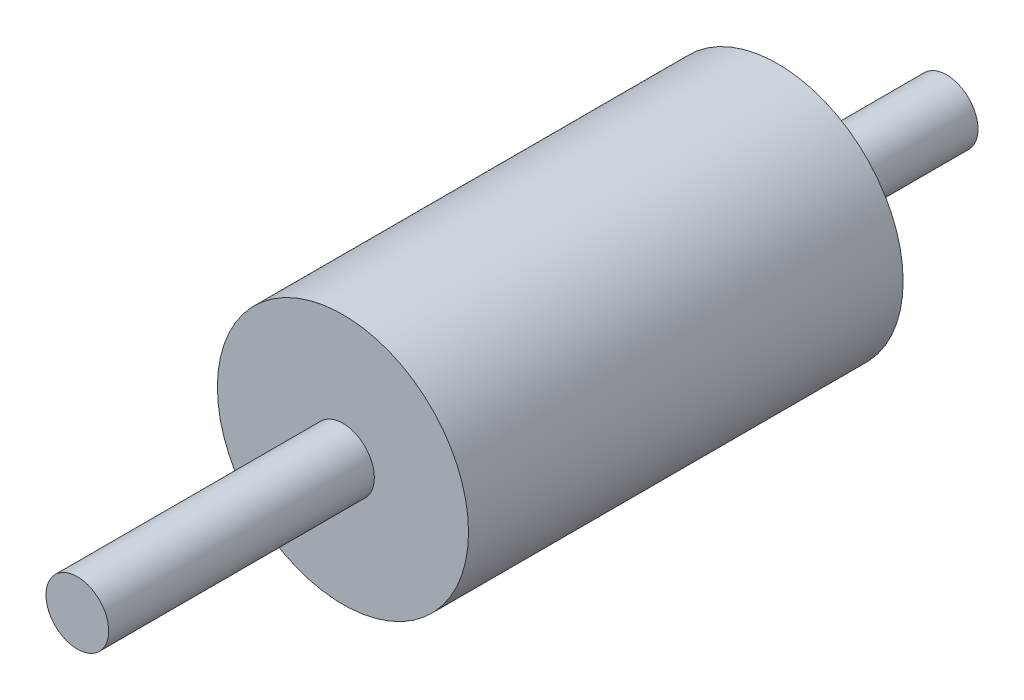
from build123d import *

# Parameters (mm, degrees)
SKETCH_1_R           = 0.65
EXTRUDE_1_DEPTH      = 10
EXTRUDE_1_DEPTH_BACK = 8
SKETCH_2_R           = 2.6
EXTRUDE_3_DEPTH      = 4.5
EXTRUDE_3_DEPTH_BACK = 4.5


with BuildPart() as part:
    # Эскиз1 → Бобышка-Вытянуть1 (new body, two sides)
    with BuildSketch(Plane.XY) as extrude_1_sk:
        Circle(SKETCH_1_R)
    extrude(amount=EXTRUDE_1_DEPTH)
    extrude(extrude_1_sk.sketch, amount=-EXTRUDE_1_DEPTH_BACK)

    # Эскиз2 → Бобышка-Вытянуть3 (add, two sides)
    with BuildSketch(Plane.XY) as extrude_3_sk:
        Circle(SKETCH_2_R)
    extrude(amount=EXTRUDE_3_DEPTH)
    extrude(extrude_3_sk.sketch, amount=-EXTRUDE_3_DEPTH_BACK)


solid = part.part
